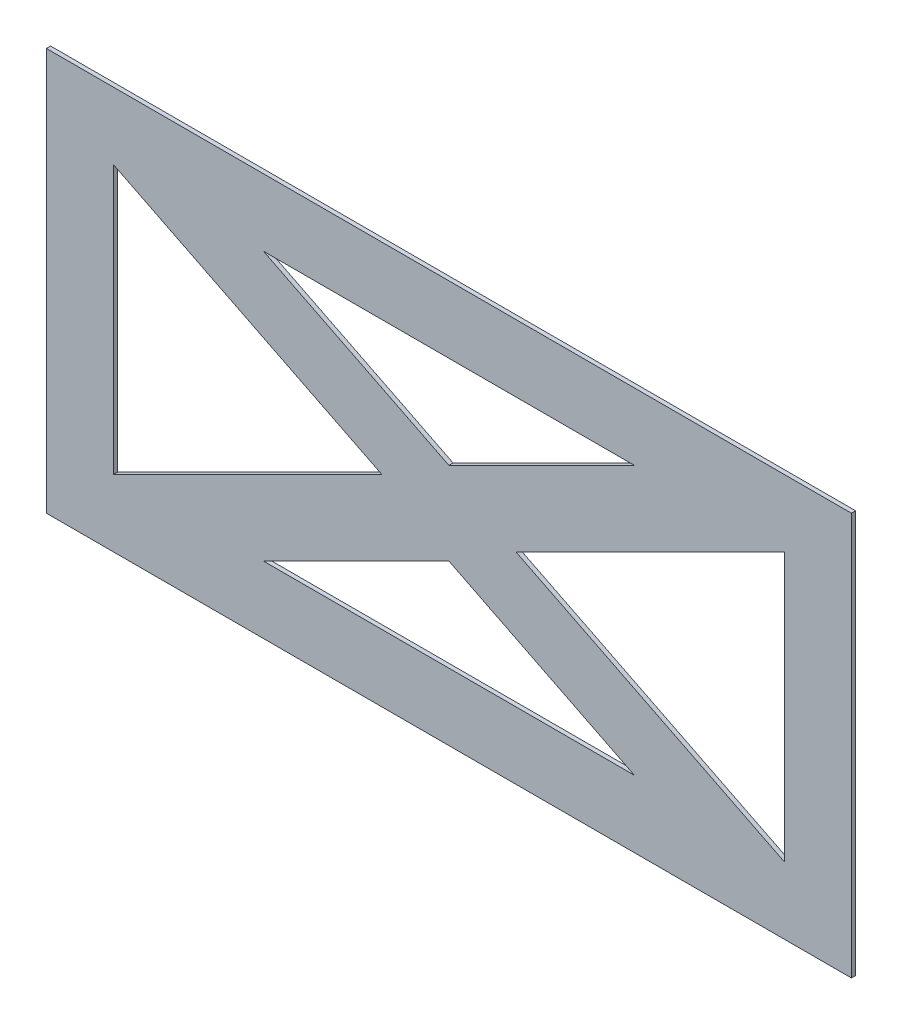
from build123d import *

# Parameters (mm, degrees)
SKETCH1_W           = 304.8
SKETCH1_H           = 152.4
BOSS_EXTRUDE1_DEPTH = 0.79375


with BuildPart() as part:
    # Sketch1 → Boss-Extrude1 (new body, symmetric)
    with BuildSketch(Plane.XY):
        Rectangle(SKETCH1_W, SKETCH1_H)
        Polygon((-127, 50.8), (-127, -50.8), (-25.4, 0), align=None, mode=Mode.SUBTRACT)
        Polygon((-70.203873372, 50.8), (70.203873372, 50.8), (0, 15.698063314), align=None, mode=Mode.SUBTRACT)
        Polygon((0, -15.698063314), (-70.203873372, -50.8), (70.203873372, -50.8), align=None, mode=Mode.SUBTRACT)
        Polygon((25.4, 0), (127, 50.8), (127, -50.8), align=None, mode=Mode.SUBTRACT)
    extrude(amount=BOSS_EXTRUDE1_DEPTH, both=True)


solid = part.part
